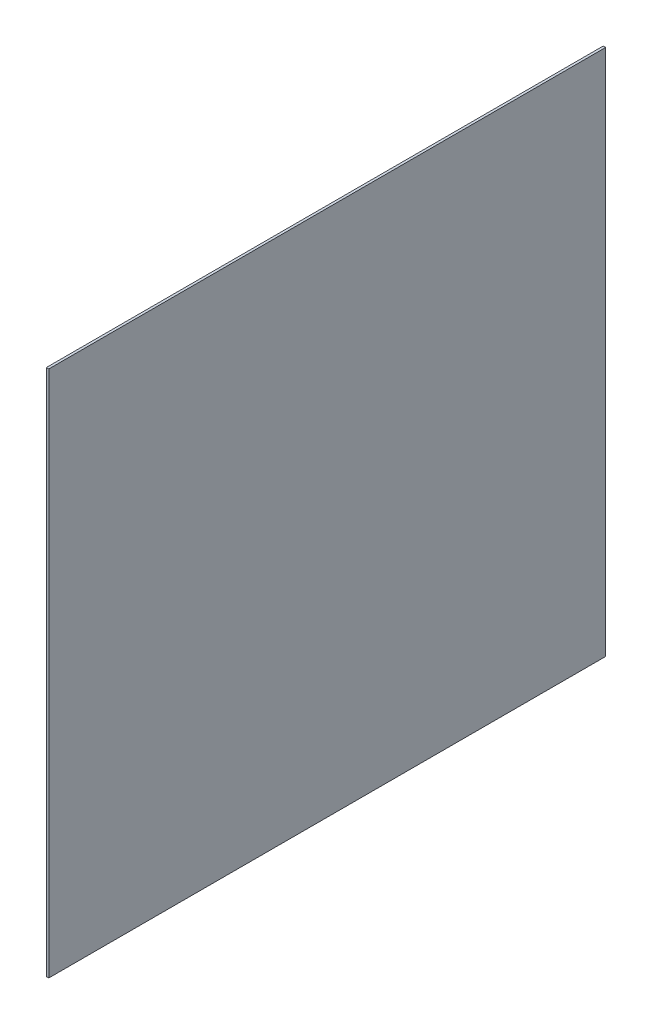
from build123d import *

# Parameters (mm, degrees)
SKETCH1_W           = 454
SKETCH1_H           = 430
BOSS_EXTRUDE1_DEPTH = 2


with BuildPart() as part:
    # Sketch1 → Boss-Extrude1 (new body)
    with BuildSketch(Plane(origin=(0, 0, 0), x_dir=(0, 0, -1), z_dir=(1, 0, 0))):
        with Locations((-118.242082369, -9.243315508)):
            Rectangle(SKETCH1_W, SKETCH1_H)
    extrude(amount=BOSS_EXTRUDE1_DEPTH)


solid = part.part
